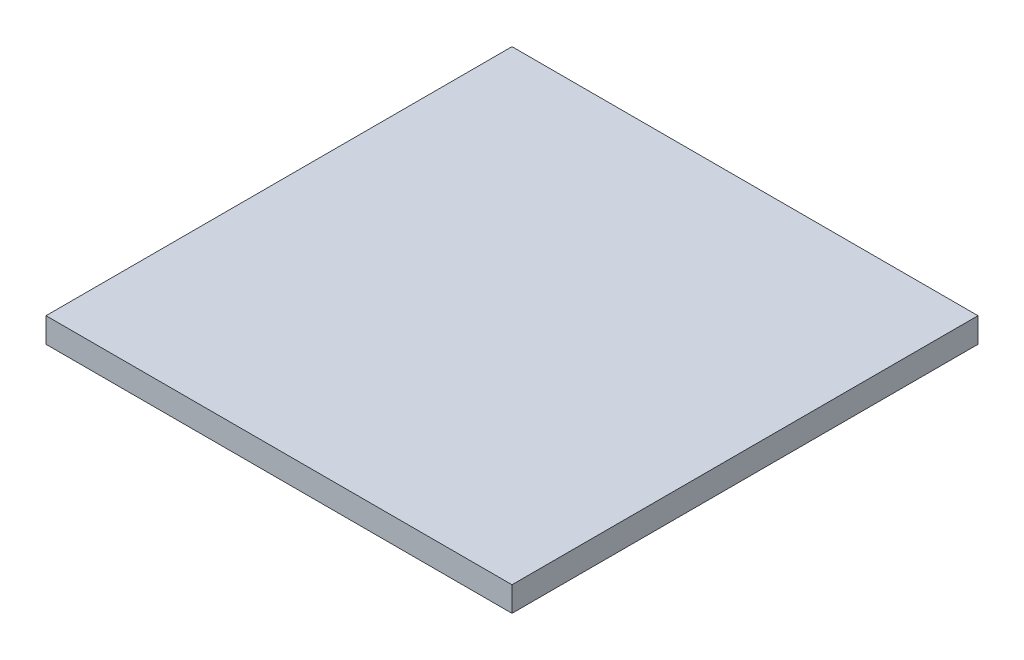
from build123d import *

# Parameters (mm, degrees)
SKETCH1_W           = 62
SKETCH1_H           = 62
BOSS_EXTRUDE1_DEPTH = 3.3


with BuildPart() as part:
    # Sketch1 → Boss-Extrude1 (new body)
    with BuildSketch(Plane(origin=(0, 0, 0), x_dir=(1, 0, 0), z_dir=(0, 1, 0))):
        with Locations((-12.313097572, -5.64689323)):
            Rectangle(SKETCH1_W, SKETCH1_H)
    extrude(amount=BOSS_EXTRUDE1_DEPTH)


solid = part.part
